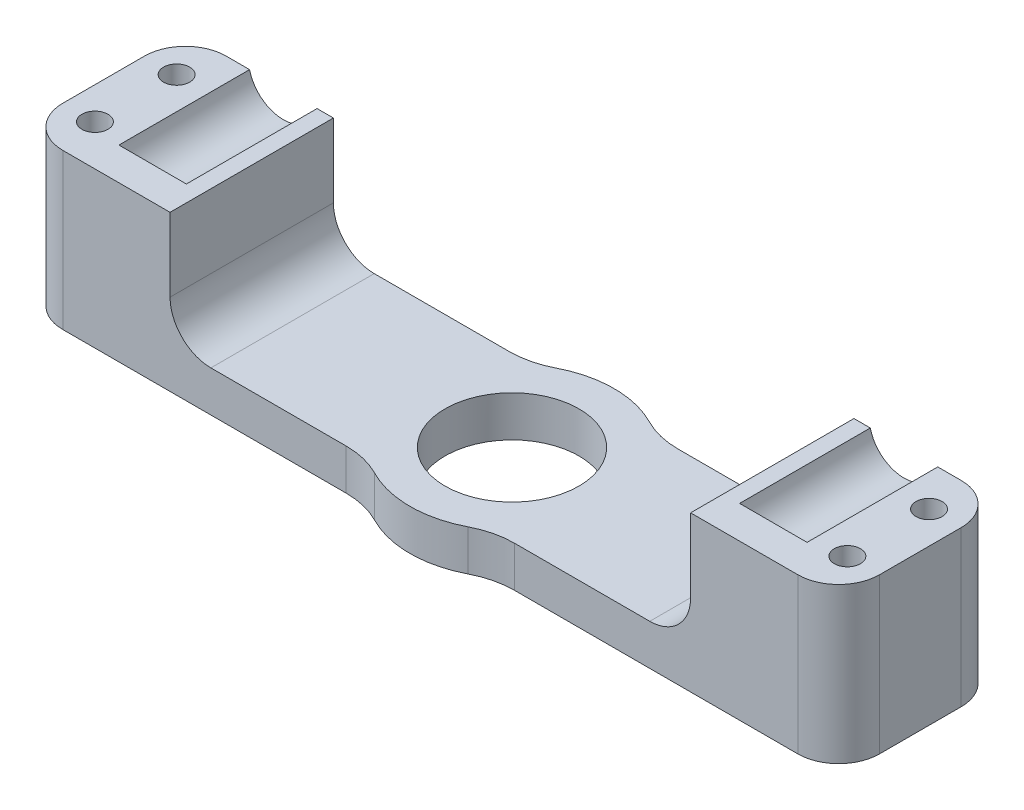
from build123d import *

# Parameters (mm, degrees)
SKETCH1_W               = 88
SKETCH1_H               = 20
BOSS_EXTRUDE1_DEPTH     = 40
SKETCH2_R               = 4.25
CUT_EXTRUDE1_DEPTH      = 21
SKETCH7_R               = 12.5
BOSS_EXTRUDE2_DEPTH     = 40
SKETCH4_R               = 8.2
CUT_EXTRUDE3_DEPTH      = 41
FILLET2_R               = 10
SKETCH9_W               = 27
SKETCH9_H               = 21
CUT_EXTRUDE4_DEPTH      = 89
SKETCH10_W              = 63.73864418
SKETCH10_H              = 16
CUT_EXTRUDE5_DEPTH      = 13.5
CUT_EXTRUDE5_DEPTH_BACK = 13.5
FILLET3_R               = 5
SKETCH11_W              = 20
SKETCH11_H              = 19
BOSS_EXTRUDE3_DEPTH     = 6
SKETCH12_R              = 1.6
CUT_EXTRUDE6_DEPTH      = 20
FILLET5_R               = 5
BOSS_EXTRUDE4_DEPTH     = 4


with BuildPart() as part:
    # Sketch1 → Boss-Extrude1 (new body)
    with BuildSketch(Plane(origin=(0, 0, 0), x_dir=(1, 0, 0), z_dir=(0, 1, 0))):
        Rectangle(SKETCH1_W, SKETCH1_H)
    extrude(amount=BOSS_EXTRUDE1_DEPTH)

    # Sketch2 → Cut-Extrude1 (cut, through all)
    with BuildSketch(Plane.XY.offset(10)):
        with Locations((-38, 20)):
            Circle(SKETCH2_R)
        with Locations((38, 20)):
            Circle(SKETCH2_R)
    extrude(amount=-CUT_EXTRUDE1_DEPTH, mode=Mode.SUBTRACT)

    # Sketch7 → Boss-Extrude2 (add)
    with BuildSketch(Plane(origin=(0, 40, 0), x_dir=(1, 0, 0), z_dir=(0, 1, 0))):
        Circle(SKETCH7_R)
    extrude(amount=-BOSS_EXTRUDE2_DEPTH)

    # Sketch4 → Cut-Extrude3 (cut, through all)
    with BuildSketch(Plane(origin=(0, 40, 0), x_dir=(1, 0, 0), z_dir=(0, 1, 0))):
        Circle(SKETCH4_R)
    extrude(amount=-CUT_EXTRUDE3_DEPTH, mode=Mode.SUBTRACT)

    # Fillet2
    fillet2_edges = [part.edges().sort_by_distance(p)[0] for p in [
        (7.5, 20, -10),
        (7.5, 20, 10),
        (-7.5, 20, -10),
        (-7.5, 20, 10),
    ]]
    fillet(fillet2_edges, radius=FILLET2_R)

    # Sketch9 → Cut-Extrude4 (cut, through all)
    with BuildSketch(Plane.ZY.offset(44)):
        with Locations((0, 29.5)):
            Rectangle(SKETCH9_W, SKETCH9_H)
    extrude(amount=-CUT_EXTRUDE4_DEPTH, mode=Mode.SUBTRACT)

    # Sketch10 → Cut-Extrude5 (cut, two sides)
    with BuildSketch(Plane.XY) as cut_extrude5_sk:
        with Locations((0, 13)):
            Rectangle(SKETCH10_W, SKETCH10_H)
    extrude(amount=CUT_EXTRUDE5_DEPTH, mode=Mode.SUBTRACT)
    extrude(cut_extrude5_sk.sketch, amount=-CUT_EXTRUDE5_DEPTH_BACK, mode=Mode.SUBTRACT)

    # Fillet3
    fillet3_edges = [part.edges().sort_by_distance(p)[0] for p in [
        (31.86932209, 5, 0),
        (-31.86932209, 5, 0),
    ]]
    fillet(fillet3_edges, radius=FILLET3_R)

    # Sketch11 → Boss-Extrude3 (add)
    with BuildSketch(Plane(origin=(44, 0, 0), x_dir=(0, 0, -1), z_dir=(1, 0, 0))):
        with Locations((0, 9.5)):
            Rectangle(SKETCH11_W, SKETCH11_H)
    boss_extrude3 = extrude(amount=BOSS_EXTRUDE3_DEPTH)

    # Sketch12 → Cut-Extrude6 (cut, through all)
    with BuildSketch(Plane(origin=(0, 19, 0), x_dir=(1, 0, 0), z_dir=(0, 1, 0))):
        with Locations((46.065338955, 5)):
            Circle(SKETCH12_R)
        with Locations((46.065338955, -5)):
            Circle(SKETCH12_R)
    cut_extrude6 = extrude(amount=-CUT_EXTRUDE6_DEPTH, mode=Mode.SUBTRACT)

    # Mirror1: Boss-Extrude3, Cut-Extrude6 across plane
    add(boss_extrude3.mirror(Plane(origin=(0, 0, 0), x_dir=(0, 0, 1), z_dir=(1, 0, 0))))
    add(cut_extrude6.mirror(Plane(origin=(0, 0, 0), x_dir=(0, 0, 1), z_dir=(1, 0, 0))), mode=Mode.SUBTRACT)

    # Fillet5
    fillet5_edges = [part.edges().sort_by_distance(p)[0] for p in [
        (50, 9.5, -10),
        (50, 9.5, 10),
        (-50, 9.5, 10),
        (-50, 9.5, -10),
    ]]
    fillet(fillet5_edges, radius=FILLET5_R)

    # Sketch13 → Boss-Extrude4 (add)
    with BuildSketch(Plane.XY.offset(10)):
        with BuildLine():
            Line((-42.13067791, 19), (-33.86932209, 19))
            ThreePointArc((-33.86932209, 19), (-38, 15.75), (-42.13067791, 19))
        make_face()
        with BuildLine():
            Line((33.86932209, 19), (42.13067791, 19))
            ThreePointArc((42.13067791, 19), (38, 15.75), (33.86932209, 19))
        make_face()
    extrude(amount=-BOSS_EXTRUDE4_DEPTH)


solid = part.part
